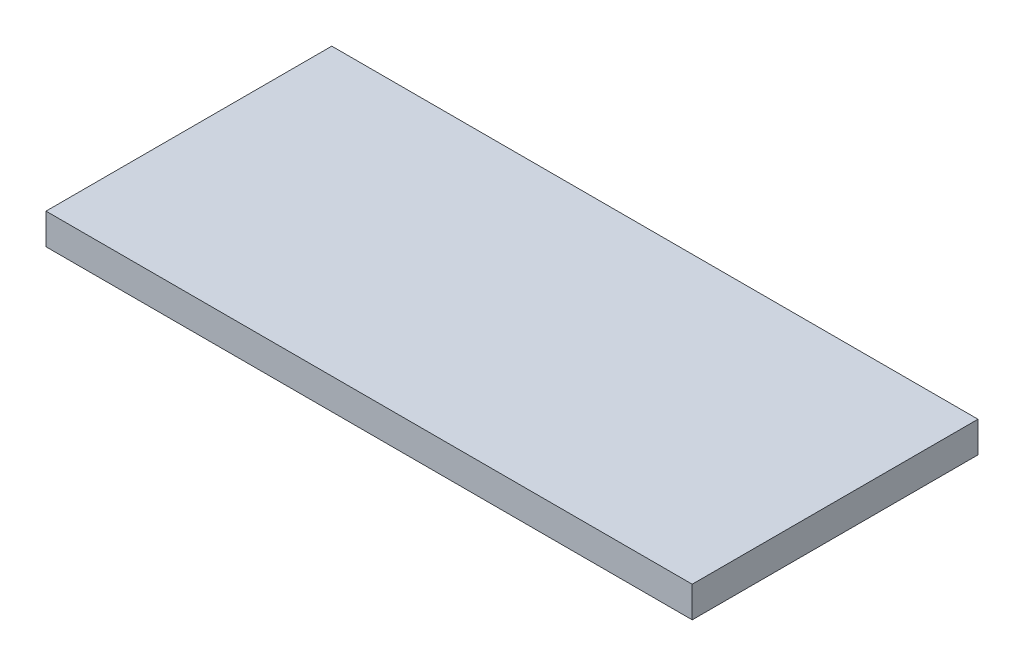
from build123d import *

# Parameters (mm, degrees)
SKETCH1_W           = 125.5
SKETCH1_H           = 55.5
BOSS_EXTRUDE1_DEPTH = 6


with BuildPart() as part:
    # Sketch1 → Boss-Extrude1 (new body)
    with BuildSketch(Plane(origin=(0, 0, 0), x_dir=(1, 0, 0), z_dir=(0, 1, 0))):
        Rectangle(SKETCH1_W, SKETCH1_H)
    extrude(amount=BOSS_EXTRUDE1_DEPTH)


solid = part.part
